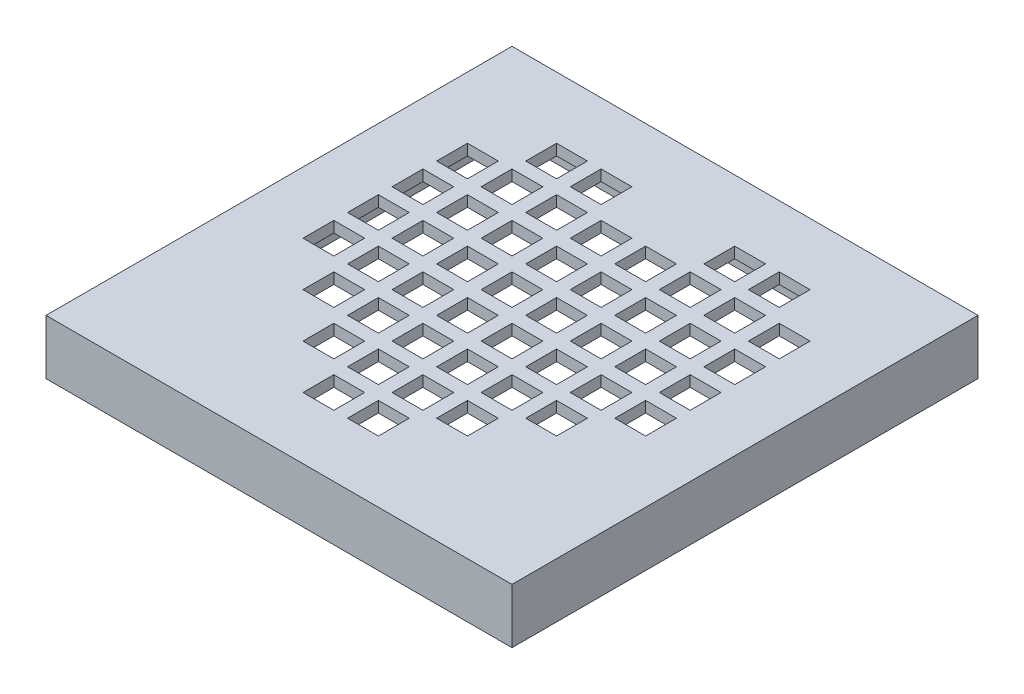
from build123d import *

# Parameters (mm, degrees)
SKETCH1_W           = 17
SKETCH1_H           = 17
BOSS_EXTRUDE1_DEPTH = 2
SKETCH2_W           = 15.2
SKETCH2_H           = 15.2
CUT_EXTRUDE1_DEPTH  = 1.6
SKETCH3_W           = 1.125
SKETCH3_H           = 1.125
CUT_EXTRUDE2_DEPTH  = 3


with BuildPart() as part:
    # Sketch1 → Boss-Extrude1 (new body)
    with BuildSketch(Plane(origin=(0, 0, 0), x_dir=(1, 0, 0), z_dir=(0, 1, 0))):
        Rectangle(SKETCH1_W, SKETCH1_H)
    extrude(amount=BOSS_EXTRUDE1_DEPTH)

    # Sketch2 → Cut-Extrude1 (cut)
    with BuildSketch(Plane.XZ):
        Rectangle(SKETCH2_W, SKETCH2_H)
    extrude(amount=-CUT_EXTRUDE1_DEPTH, mode=Mode.SUBTRACT)

    # Sketch3 → Cut-Extrude2 (cut, through all)
    with BuildSketch(Plane(origin=(0, 2, 0), x_dir=(1, 0, 0), z_dir=(0, 1, 0))):
        with Locations((-4.0625, 5.6875)):
            Rectangle(SKETCH3_W, SKETCH3_H)
        with Locations((-2.4375, 5.6875)):
            Rectangle(SKETCH3_W, SKETCH3_H)
        with Locations((2.4375, 5.6875)):
            Rectangle(SKETCH3_W, SKETCH3_H)
        with Locations((4.0625, 5.6875)):
            Rectangle(SKETCH3_W, SKETCH3_H)
        with Locations((5.6875, 4.0625)):
            Rectangle(SKETCH3_W, SKETCH3_H)
        with Locations((5.6875, 2.4375)):
            Rectangle(SKETCH3_W, SKETCH3_H)
        with Locations((5.6875, 0.8125)):
            Rectangle(SKETCH3_W, SKETCH3_H)
        with Locations((-5.6875, 4.0625)):
            Rectangle(SKETCH3_W, SKETCH3_H)
        with Locations((-5.6875, 2.4375)):
            Rectangle(SKETCH3_W, SKETCH3_H)
        with Locations((-5.6875, 0.8125)):
            Rectangle(SKETCH3_W, SKETCH3_H)
        with Locations((-4.0625, -0.8125)):
            Rectangle(SKETCH3_W, SKETCH3_H)
        with Locations((-2.4375, -2.4375)):
            Rectangle(SKETCH3_W, SKETCH3_H)
        with Locations((-0.8125, -4.0625)):
            Rectangle(SKETCH3_W, SKETCH3_H)
        with Locations((0.8125, -4.0625)):
            Rectangle(SKETCH3_W, SKETCH3_H)
        with Locations((2.4375, -2.4375)):
            Rectangle(SKETCH3_W, SKETCH3_H)
        with Locations((4.0625, -0.8125)):
            Rectangle(SKETCH3_W, SKETCH3_H)
        with Locations((-0.8125, 4.0625)):
            Rectangle(SKETCH3_W, SKETCH3_H)
        with Locations((0.8125, 4.0625)):
            Rectangle(SKETCH3_W, SKETCH3_H)
        with Locations((-4.0625, 4.0625)):
            Rectangle(SKETCH3_W, SKETCH3_H)
        with Locations((-4.0625, 2.4375)):
            Rectangle(SKETCH3_W, SKETCH3_H)
        with Locations((-2.4375, 0.8125)):
            Rectangle(SKETCH3_W, SKETCH3_H)
        with Locations((-2.4375, 2.4375)):
            Rectangle(SKETCH3_W, SKETCH3_H)
        with Locations((-2.4375, 4.0625)):
            Rectangle(SKETCH3_W, SKETCH3_H)
        with Locations((-0.8125, 2.4375)):
            Rectangle(SKETCH3_W, SKETCH3_H)
        with Locations((0.8125, 2.4375)):
            Rectangle(SKETCH3_W, SKETCH3_H)
        with Locations((2.4375, 0.8125)):
            Rectangle(SKETCH3_W, SKETCH3_H)
        with Locations((2.4375, 2.4375)):
            Rectangle(SKETCH3_W, SKETCH3_H)
        with Locations((2.4375, 4.0625)):
            Rectangle(SKETCH3_W, SKETCH3_H)
        with Locations((4.0625, 2.4375)):
            Rectangle(SKETCH3_W, SKETCH3_H)
        with Locations((4.0625, 0.8125)):
            Rectangle(SKETCH3_W, SKETCH3_H)
        with Locations((2.4375, -0.8125)):
            Rectangle(SKETCH3_W, SKETCH3_H)
        with Locations((0.8125, -0.8125)):
            Rectangle(SKETCH3_W, SKETCH3_H)
        with Locations((-2.4375, -0.8125)):
            Rectangle(SKETCH3_W, SKETCH3_H)
        with Locations((-0.8125, -2.4375)):
            Rectangle(SKETCH3_W, SKETCH3_H)
        with Locations((0.8125, -2.4375)):
            Rectangle(SKETCH3_W, SKETCH3_H)
        with Locations((-0.8125, -0.8125)):
            Rectangle(SKETCH3_W, SKETCH3_H)
        with Locations((-4.0625, 0.8125)):
            Rectangle(SKETCH3_W, SKETCH3_H)
        with Locations((-0.8125, 0.8125)):
            Rectangle(SKETCH3_W, SKETCH3_H)
        with Locations((0.8125, 0.8125)):
            Rectangle(SKETCH3_W, SKETCH3_H)
        with Locations((4.0625, 4.0625)):
            Rectangle(SKETCH3_W, SKETCH3_H)
        with Locations((5.6875, -0.8125)):
            Rectangle(SKETCH3_W, SKETCH3_H)
        with Locations((4.0625, -2.4375)):
            Rectangle(SKETCH3_W, SKETCH3_H)
        with Locations((2.4375, -4.0625)):
            Rectangle(SKETCH3_W, SKETCH3_H)
        with Locations((0.8125, -5.6875)):
            Rectangle(SKETCH3_W, SKETCH3_H)
        with Locations((-0.8125, -5.6875)):
            Rectangle(SKETCH3_W, SKETCH3_H)
        with Locations((-2.4375, -4.0625)):
            Rectangle(SKETCH3_W, SKETCH3_H)
        with Locations((-4.0625, -2.4375)):
            Rectangle(SKETCH3_W, SKETCH3_H)
        with Locations((-5.6875, -0.8125)):
            Rectangle(SKETCH3_W, SKETCH3_H)
    extrude(amount=-CUT_EXTRUDE2_DEPTH, mode=Mode.SUBTRACT)


solid = part.part
